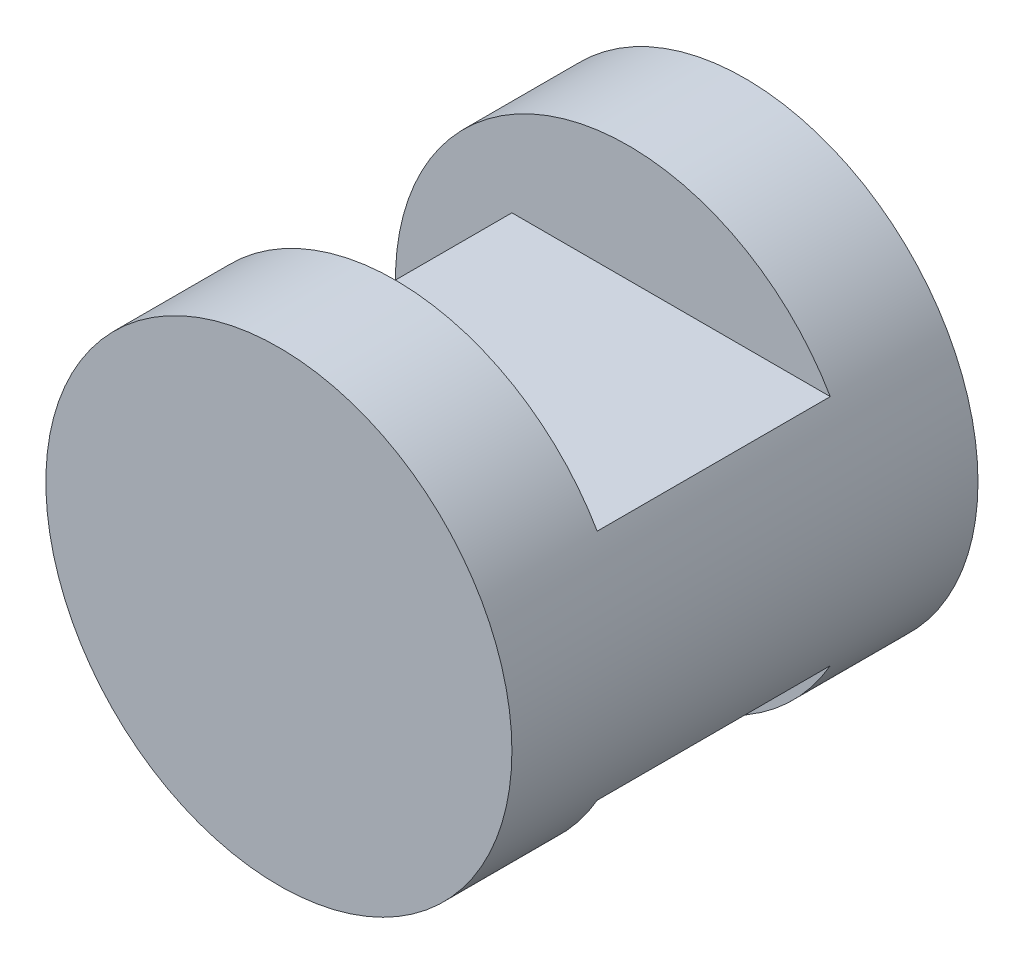
from build123d import *

# Parameters (mm, degrees)
SKETCH1_R               = 20
BOSS_EXTRUDE1_DEPTH     = 40
CUT_EXTRUDE1_DEPTH      = 40
CUT_EXTRUDE1_DEPTH_BACK = 40
SKETCH2_W               = 10
SKETCH2_H               = 20
CUT_EXTRUDE2_DEPTH      = 40
CUT_EXTRUDE2_DEPTH_BACK = 40
SKETCH3_W               = 20
SKETCH3_H               = 10


with BuildPart() as part:
    # Sketch1 → Boss-Extrude1 (new body)
    with BuildSketch(Plane.XY):
        Circle(SKETCH1_R)
    extrude(amount=BOSS_EXTRUDE1_DEPTH)

    # Sketch2 → Cut-Extrude1 (cut, two sides: drawn at the far end of the back side and taken through both)
    with BuildSketch(Plane(origin=(0, 0, 0), x_dir=(1, 0, 0), z_dir=(0, 1, 0)).offset(-CUT_EXTRUDE1_DEPTH_BACK)):
        with Locations((-15, -20)):
            Rectangle(SKETCH2_W, SKETCH2_H)
    extrude(amount=CUT_EXTRUDE1_DEPTH + CUT_EXTRUDE1_DEPTH_BACK, mode=Mode.SUBTRACT)

    # Sketch3 → Cut-Extrude2 (cut, two sides: drawn at the far end of the back side and taken through both)
    with BuildSketch(Plane(origin=(0, 0, 0), x_dir=(0, 0, -1), z_dir=(1, 0, 0)).offset(-CUT_EXTRUDE2_DEPTH_BACK)):
        with Locations((-20, 15)):
            Rectangle(SKETCH3_W, SKETCH3_H)
        with Locations((-20, -15)):
            Rectangle(SKETCH3_W, SKETCH3_H)
    extrude(amount=CUT_EXTRUDE2_DEPTH + CUT_EXTRUDE2_DEPTH_BACK, mode=Mode.SUBTRACT)


solid = part.part
